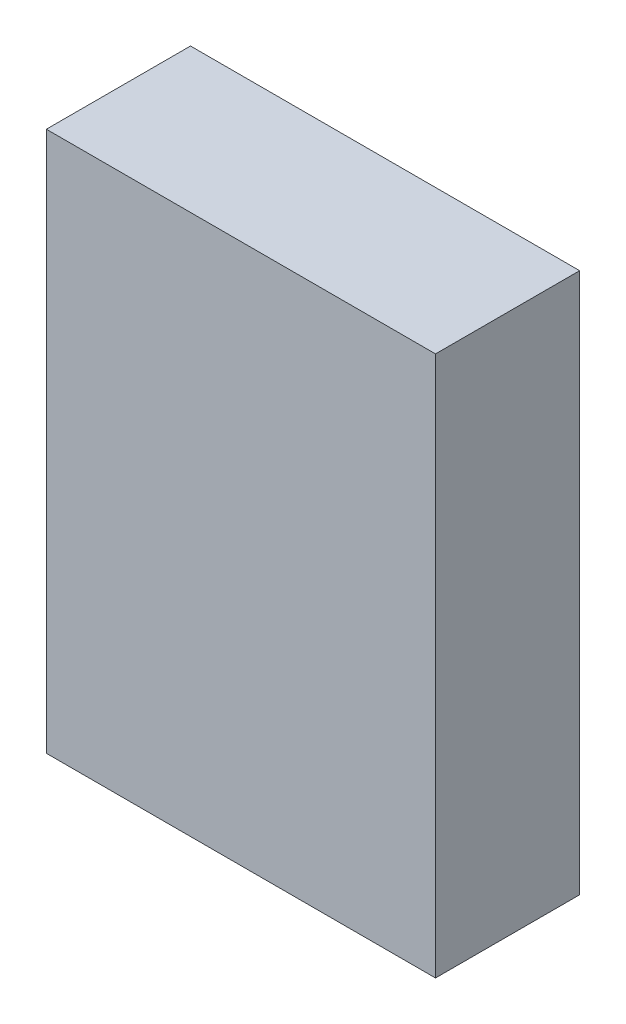
from build123d import *

# Parameters (mm, degrees)
SKETCH1_W           = 10.8
SKETCH1_H           = 15
BOSS_EXTRUDE1_DEPTH = 4


with BuildPart() as part:
    # Sketch1 → Boss-Extrude1 (new body)
    with BuildSketch(Plane.XY):
        with Locations((5.4, 7.5)):
            Rectangle(SKETCH1_W, SKETCH1_H)
    extrude(amount=BOSS_EXTRUDE1_DEPTH)


solid = part.part
